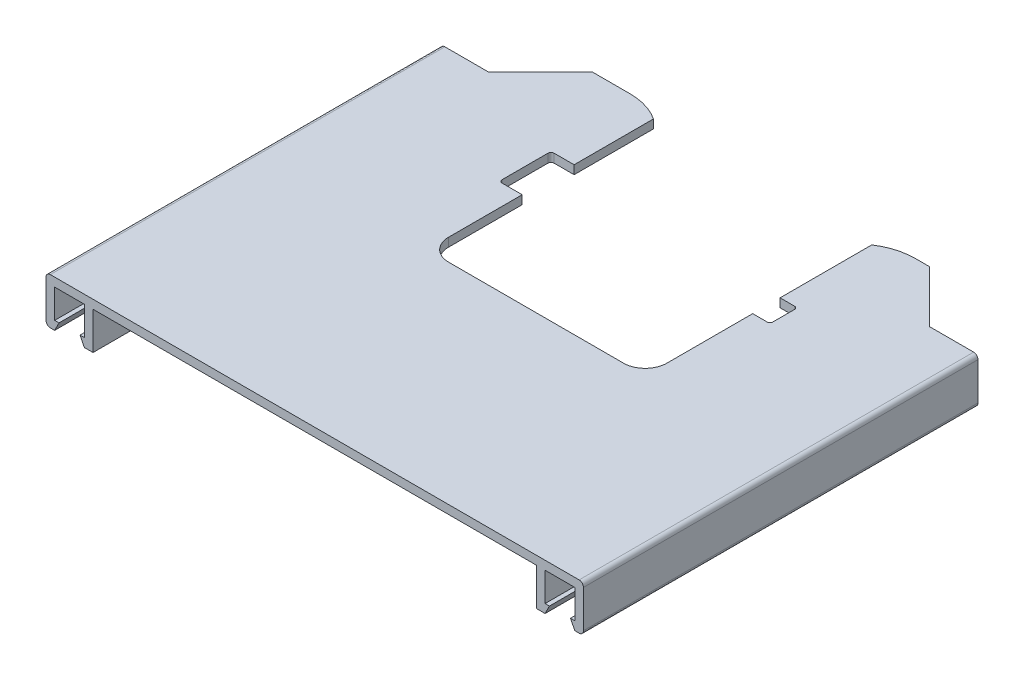
from build123d import *

# Parameters (mm, degrees)
SKETCH1_W           = 186.3
SKETCH1_H           = 72.76
BOSS_EXTRUDE1_DEPTH = 3
SKETCH3_W           = 59.3
SKETCH3_H           = 64
SKETCH3_W_2         = 51.35
BOSS_EXTRUDE3_DEPTH = 3
BOSS_EXTRUDE4_DEPTH = 3
CUT_EXTRUDE1_DEPTH  = 10
SKETCH9_W           = 3
SKETCH9_H           = 136.76
BOSS_EXTRUDE7_DEPTH = 13
FILLET1_R           = 7.5
BOSS_EXTRUDE8_DEPTH = 136.76
FILLET2_R           = 1.5


with BuildPart() as part:
    # Sketch1 → Boss-Extrude1 (new body)
    with BuildSketch(Plane(origin=(0, 0, 0), x_dir=(1, 0, 0), z_dir=(0, 1, 0))):
        with Locations((93.15, 36.38)):
            Rectangle(SKETCH1_W, SKETCH1_H)
    extrude(amount=BOSS_EXTRUDE1_DEPTH)

    # Sketch3 → Boss-Extrude3 (add)
    with BuildSketch(Plane(origin=(0, 3, 0), x_dir=(1, 0, 0), z_dir=(0, 1, 0))):
        with Locations((29.65, 104.76)):
            Rectangle(SKETCH3_W, SKETCH3_H)
        with Locations((160.625, 104.76)):
            Rectangle(SKETCH3_W_2, SKETCH3_H)
    extrude(amount=-BOSS_EXTRUDE3_DEPTH)

    # Sketch5 → Boss-Extrude4 (add)
    with BuildSketch(Plane(origin=(0, 3, 0), x_dir=(1, 0, 0), z_dir=(0, 1, 0))):
        with BuildLine():
            Line((169.56, 136.76), (151.56, 154.76))
            Line((151.56, 154.76), (146.56, 154.76))
            ThreePointArc((146.56, 154.76), (140.496954148, 153.865974954), (134.95, 151.26))
            Line((134.95, 151.26), (134.95, 136.76))
            Line((134.95, 136.76), (169.56, 136.76))
        make_face()
        with BuildLine():
            Line((59.3, 136.76), (16.69, 136.76))
            Line((16.69, 136.76), (34.69, 154.76))
            Line((34.69, 154.76), (47.69, 154.76))
            ThreePointArc((47.69, 154.76), (53.753045852, 153.865974954), (59.3, 151.26))
            Line((59.3, 151.26), (59.3, 136.76))
        make_face()
    extrude(amount=-BOSS_EXTRUDE4_DEPTH)

    # Sketch6 → Cut-Extrude1 (cut)
    with BuildSketch(Plane(origin=(0, 3, 0), x_dir=(1, 0, 0), z_dir=(0, 1, 0))):
        with BuildLine():
            Line((59.3, 123.76), (52.3, 123.76))
            ThreePointArc((52.3, 123.76), (51.592893219, 123.467106781), (51.3, 122.76))
            Line((51.3, 122.76), (51.3, 106.76))
            ThreePointArc((51.3, 106.76), (51.592893219, 106.052893219), (52.3, 105.76))
            Line((52.3, 105.76), (59.3, 105.76))
            Line((59.3, 105.76), (59.3, 123.76))
        make_face()
        with BuildLine():
            Line((139.95, 110.01), (134.95, 110.01))
            Line((134.95, 110.01), (134.95, 119.51))
            Line((134.95, 119.51), (139.95, 119.51))
            ThreePointArc((139.95, 119.51), (140.657106781, 119.217106781), (140.95, 118.51))
            Line((140.95, 118.51), (140.95, 111.01))
            ThreePointArc((140.95, 111.01), (140.657106781, 110.302893219), (139.95, 110.01))
        make_face()
    extrude(amount=-CUT_EXTRUDE1_DEPTH, mode=Mode.SUBTRACT)

    # Sketch9 → Boss-Extrude7 (add)
    with BuildSketch(Plane.XZ):
        with Locations((1.5, -68.38)):
            Rectangle(SKETCH9_W, SKETCH9_H)
        with Locations((184.8, -68.38)):
            Rectangle(SKETCH9_W, SKETCH9_H)
        with Locations((14.8, -68.38)):
            Rectangle(SKETCH9_W, SKETCH9_H)
        with Locations((171.5, -68.38)):
            Rectangle(SKETCH9_W, SKETCH9_H)
    extrude(amount=BOSS_EXTRUDE7_DEPTH)

    # Fillet1
    fillet1_edges = [part.edges().sort_by_distance(p)[0] for p in [
        (59.3, 1.5, -72.76),
        (134.95, 1.5, -72.76),
    ]]
    fillet(fillet1_edges, radius=FILLET1_R)

    # Sketch10 → Boss-Extrude8 (add)
    with BuildSketch(Plane(origin=(0, 0, -136.76), x_dir=(-1, 0, 0), z_dir=(0, 0, -1))):
        Polygon((-183.3, -13), (-181.8, -10), (-183.3, -10), align=None)
        Polygon((-174.5, -10), (-173, -10), (-173, -13), align=None)
        Polygon((-13.3, -10), (-13.3, -13), (-11.8, -10), align=None)
        Polygon((-4.5, -10), (-3, -10), (-3, -13), align=None)
    extrude(amount=-BOSS_EXTRUDE8_DEPTH)

    # Fillet2
    fillet2_edges = [part.edges().sort_by_distance(p)[0] for p in [
        (186.3, 3, -68.38),
        (0, -13, -68.38),
        (186.3, -13, -68.38),
        (0, 3, -68.38),
    ]]
    fillet(fillet2_edges, radius=FILLET2_R)


solid = part.part
